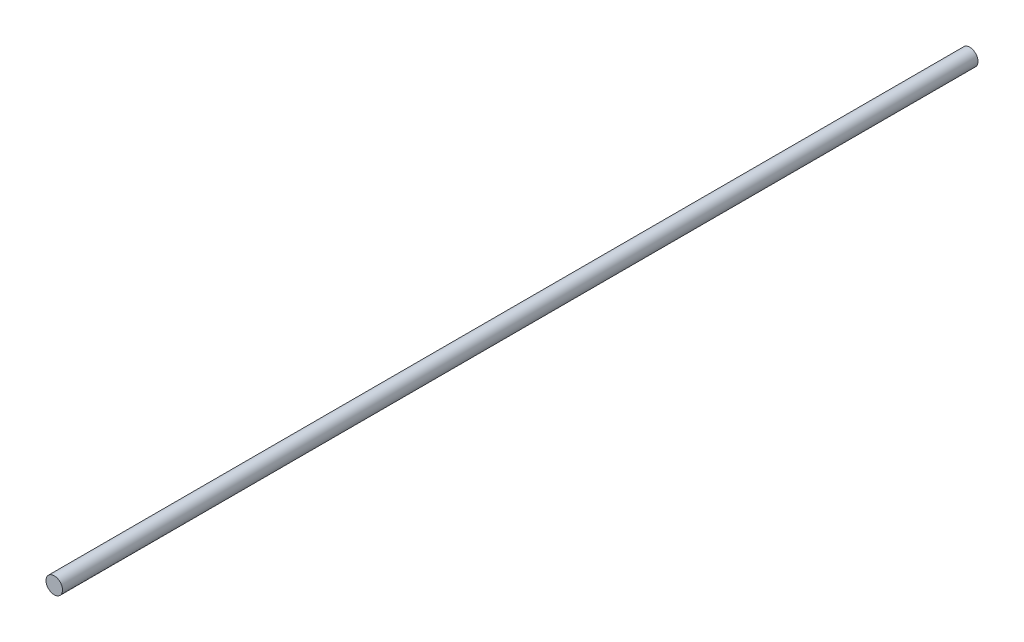
from build123d import *

# Parameters (mm, degrees)
SKETCH1_R           = 3.7970867
BOSS_EXTRUDE1_DEPTH = 421.052632


with BuildPart() as part:
    # Sketch1 → Boss-Extrude1 (new body)
    with BuildSketch(Plane.XY):
        with Locations((-4.876879261, 119.437033127)):
            Circle(SKETCH1_R)
    extrude(amount=BOSS_EXTRUDE1_DEPTH)


solid = part.part
